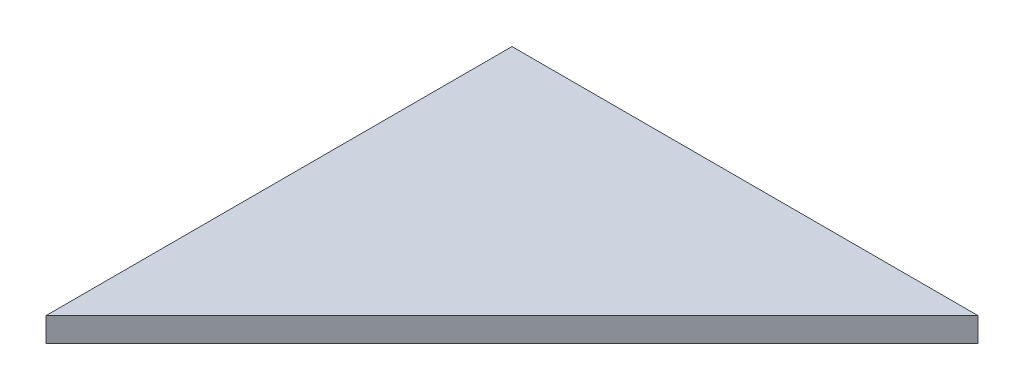
from build123d import *

# Parameters (mm, degrees)
BOSS_EXTRUDE1_DEPTH = 1.5


with BuildPart() as part:
    # Sketch1 → Boss-Extrude1 (new body, symmetric)
    with BuildSketch(Plane(origin=(0, -113.704878, 0), x_dir=(-1, 0, 0), z_dir=(0, -1, 0))):
        Polygon((-107.572775552, -49.638102576), (-49.638102576, -107.572775552), (-49.638102576, -49.638102576), align=None)
    extrude(amount=BOSS_EXTRUDE1_DEPTH, both=True)


solid = part.part
